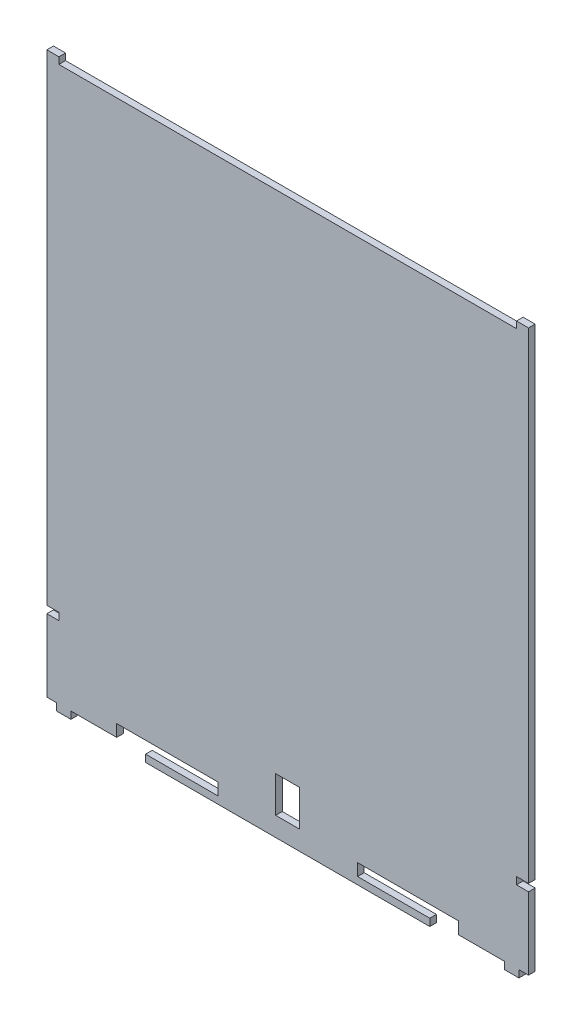
from build123d import *

# Parameters (mm, degrees)
EXTRUDE_1_DEPTH = 2.75


with BuildPart() as part:
    # 草图1 → 凸台-拉伸1 (new body)
    with BuildSketch(Plane.XY):
        Polygon((200, 0), (200, 27), (200, 30), (195, 30), (195, 33), (200, 33), (200, 230), (200, 232.75), (195, 232.75), (195, 230), (5, 230), (5, 232.75), (0, 232.75), (0, 230), (0, 33), (5, 33), (5, 30), (0, 30), (0, 27), (0, 0), (4, 0), (4, -3), (10, -3), (10, 0), (29, 0), (29, 5), (71, 5), (71, 0), (41, 0), (41, -3), (159, -3), (159, 0), (129, 0), (129, 5), (171, 5), (171, 0), (190, 0), (190, -3), (196, -3), (196, 0), align=None)
        Polygon((95, 5), (100, 5), (105, 5), (105, 20), (95, 20), align=None, mode=Mode.SUBTRACT)
    extrude(amount=EXTRUDE_1_DEPTH)


solid = part.part
